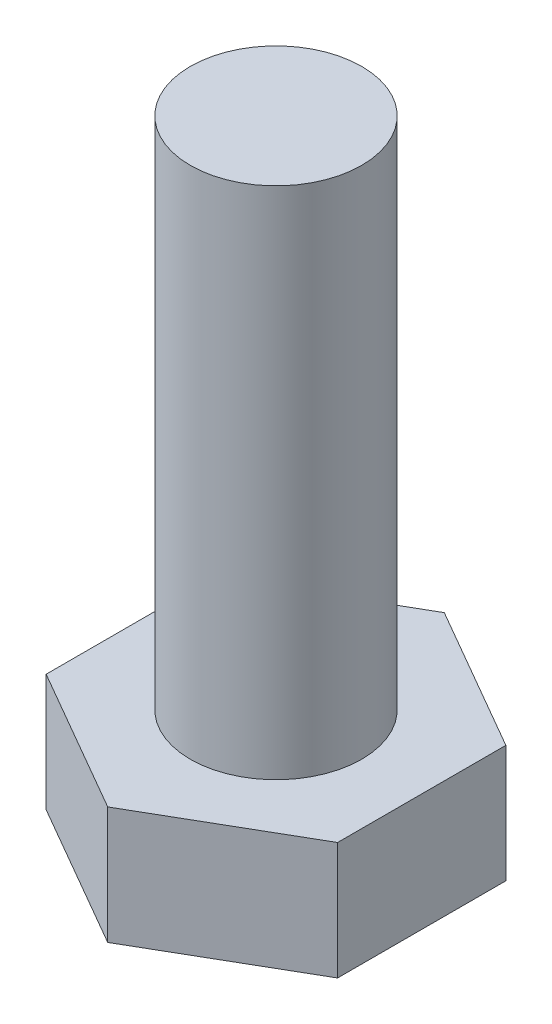
from build123d import *

# Parameters (mm, degrees)
EXTRUDE_1_DEPTH = 8
SKETCH_2_R      = 5
EXTRUDE_2_DEPTH = 30
CHAMFER_1_SIZE  = 2
CHAMFER_1_SIZE2 = 1.154700538


with BuildPart() as part:
    # Эскиз1 → Бобышка-Вытянуть1 (new body)
    with BuildSketch(Plane(origin=(0, 0, 0), x_dir=(1, 0, 0), z_dir=(0, 1, 0))):
        Polygon((8.5, -4.907477288), (8.5, 4.907477288), (0, 9.814954576), (-8.5, 4.907477288), (-8.5, -4.907477288), (0, -9.814954576), align=None)
    extrude(amount=EXTRUDE_1_DEPTH)

    # Эскиз2 → Бобышка-Вытянуть2 (add)
    with BuildSketch(Plane(origin=(0, 8, 0), x_dir=(1, 0, 0), z_dir=(0, 1, 0))):
        Circle(SKETCH_2_R)
    extrude(amount=EXTRUDE_2_DEPTH)

    # Фаска1
    chamfer_1_edges = [part.edges().sort_by_distance(p)[0] for p in [
        (-4.25, 0, 7.361215932),
        (-8.5, 0, 0),
        (-4.25, 0, -7.361215932),
        (4.25, 0, -7.361215932),
        (8.5, 0, 0),
        (4.25, 0, 7.361215932),
    ]]
    chamfer_1_side = [part.faces().sort_by_distance(p)[0] for p in [
        (0, 0, 0),
    ]]
    chamfer(chamfer_1_edges, length=CHAMFER_1_SIZE, length2=CHAMFER_1_SIZE2, reference=chamfer_1_side[0])


solid = part.part
